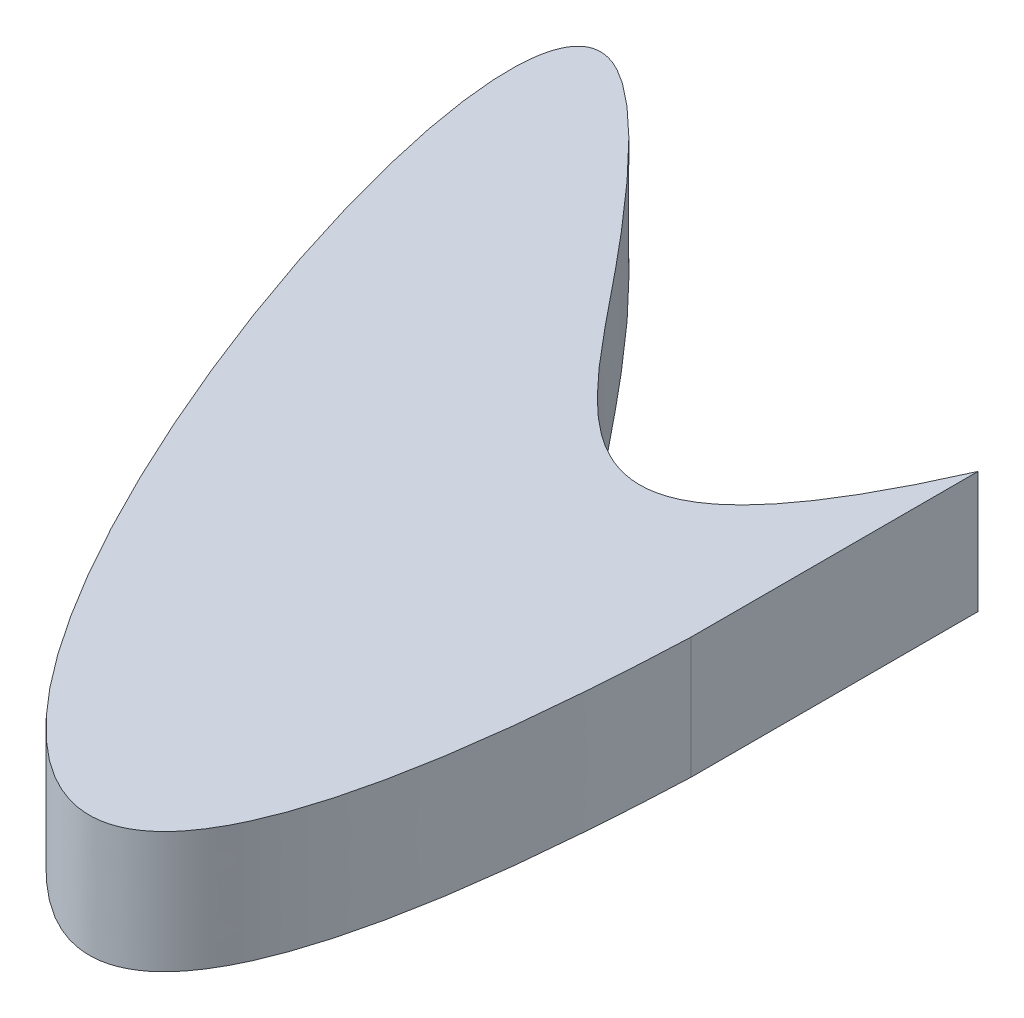
from build123d import *

# Parameters (mm, degrees)
BOSS_EXTRUDE1_DEPTH = 6.35


with BuildPart() as part:
    # Sketch2 → Boss-Extrude1 (new body)
    with BuildSketch(Plane(origin=(0, 0, 0), x_dir=(1, 0, 0), z_dir=(0, 1, 0))):
        with BuildLine():
            Line((0, 4.18579954), (0, -10.81420046))
            add(Edge.make_bspline(
                [(0, -10.81420046), (-2.660850973, -77.829737833), (-47.069069638, 35.862057749), (-14.51375469, -0.363021623), (-7.061127273, -11.877060088), (0, 4.18579954)],
                knots=[0, 0, 0, 0, 0.654969788, 0.773193611, 1, 1, 1, 1], degree=3))
        make_face()
    extrude(amount=BOSS_EXTRUDE1_DEPTH)


solid = part.part
